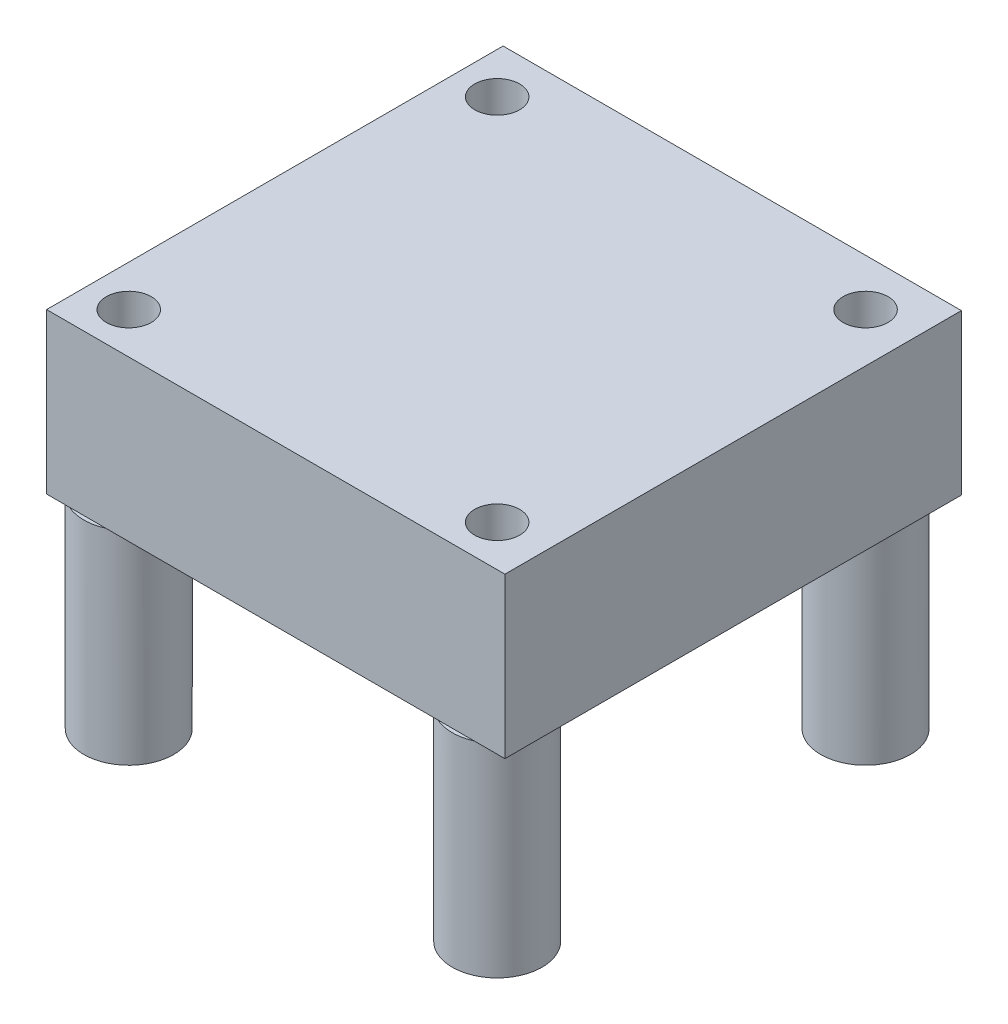
from build123d import *

# Parameters (mm, degrees)
SKETCH1_W           = 25.5
SKETCH1_H           = 25.4
BOSS_EXTRUDE1_DEPTH = 8.89
SKETCH2_R           = 2.5
BOSS_EXTRUDE2_DEPTH = 11.303
SKETCH3_R           = 1.25
CUT_EXTRUDE1_DEPTH  = 21.193


with BuildPart() as part:
    # Sketch1 → Boss-Extrude1 (new body)
    with BuildSketch(Plane(origin=(0, 0, 0), x_dir=(1, 0, 0), z_dir=(0, 1, 0))):
        with Locations((-4.113944862, -1.223942607)):
            Rectangle(SKETCH1_W, SKETCH1_H)
    extrude(amount=BOSS_EXTRUDE1_DEPTH)

    # Sketch2 → Boss-Extrude2 (add)
    with BuildSketch(Plane.XZ):
        with Locations((-14.577944862, 11.637942607)):
            Circle(SKETCH2_R)
        with Locations((5.919855138, 11.637942607)):
            Circle(SKETCH2_R)
        with Locations((5.919855138, -8.859857393)):
            Circle(SKETCH2_R)
        with Locations((-14.577944862, -8.859857393)):
            Circle(SKETCH2_R)
    extrude(amount=BOSS_EXTRUDE2_DEPTH)

    # Sketch3 → Cut-Extrude1 (cut, through all)
    with BuildSketch(Plane.XZ.offset(11.303)):
        with Locations((-14.577944862, 11.637942607)):
            Circle(SKETCH3_R)
        with Locations((-14.577944862, -8.859857393)):
            Circle(SKETCH3_R)
        with Locations((5.919855138, -8.859857393)):
            Circle(SKETCH3_R)
        with Locations((5.919855138, 11.637942607)):
            Circle(SKETCH3_R)
    extrude(amount=-CUT_EXTRUDE1_DEPTH, mode=Mode.SUBTRACT)


solid = part.part
